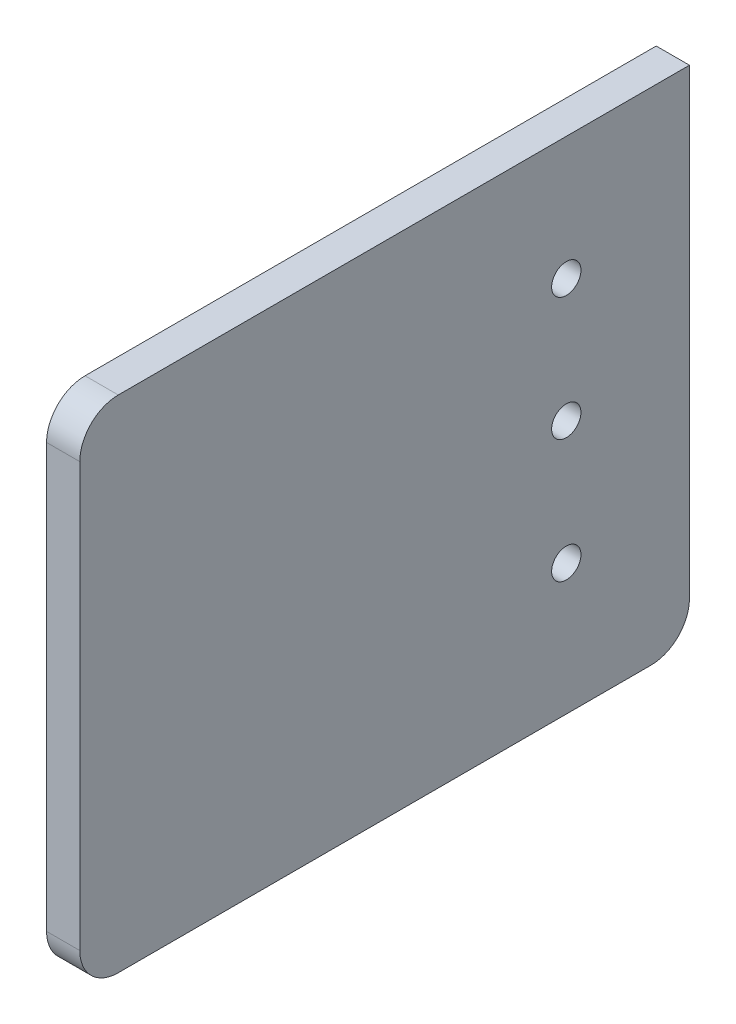
from build123d import *

# Parameters (mm, degrees)
SKETCH1_W           = 79.195959493
SKETCH1_H           = 65
SKETCH1_R           = 1.905
BOSS_EXTRUDE1_DEPTH = 4.318
FILLET1_R           = 5


with BuildPart() as part:
    # Sketch1 → Boss-Extrude1 (new body)
    with BuildSketch(Plane(origin=(0, 0, 0), x_dir=(0, 0, -1), z_dir=(1, 0, 0))):
        with Locations((39.597979747, 32.5)):
            Rectangle(SKETCH1_W, SKETCH1_H)
        with Locations((63.195959493, 49)):
            Circle(SKETCH1_R, mode=Mode.SUBTRACT)
        with Locations((63.195959493, 33)):
            Circle(SKETCH1_R, mode=Mode.SUBTRACT)
        with Locations((63.195959493, 17)):
            Circle(SKETCH1_R, mode=Mode.SUBTRACT)
    extrude(amount=BOSS_EXTRUDE1_DEPTH)

    # Fillet1
    fillet1_edges = [part.edges().sort_by_distance(p)[0] for p in [
        (2.159, 65, 0),
        (2.159, 0, 0),
        (2.159, 0, -79.195959493),
    ]]
    fillet(fillet1_edges, radius=FILLET1_R)


solid = part.part
